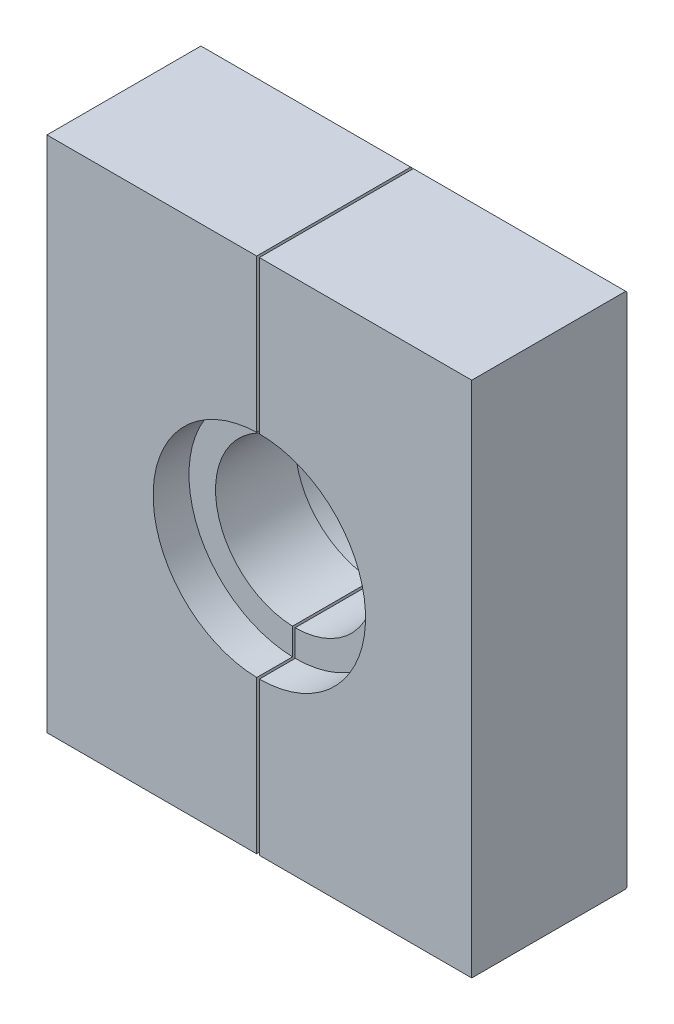
from build123d import *

# Parameters (mm, degrees)
SKICA1_W                  = 32
SKICA1_H                  = 39
SKICA1_R                  = 8
SKICA1_R_2                = 6
P_IDAT_VYSUNUT_M1_DEPTH   = 12.7
SKICA3_R                  = 8
ODEBRAT_VYSUNUT_M2_DEPTH  = 3.7
SKICA4_R                  = 8
ODEBRAT_VYSUNUT_M3_DEPTH  = 3
ZKOSEN_1_SIZE             = 0.1
ODEBRAT_START             = -12.7
SKICA10_W                 = 0.2
SKICA10_H                 = 39
ODEBRAT_VYSUNUT_M13_DEPTH = 12.7
SKETCH1_W                 = 58.510416229
SKETCH1_H                 = 45.106423975
CUT_EXTRUDE1_DEPTH        = 1


with BuildPart() as part:
    # Skica1 → Přidat vysunutím1 (new body)
    with BuildSketch(Plane.XY):
        with Locations((-2.081569801, -7.5)):
            Rectangle(SKICA1_W, SKICA1_H)
        with Locations((-2.081569801, -7.5)):
            Circle(SKICA1_R, mode=Mode.SUBTRACT)
        with Locations((-2.081569801, -7.5)):
            Circle(SKICA1_R)
        with Locations((-2.081569801, -7.5)):
            Circle(SKICA1_R_2, mode=Mode.SUBTRACT)
    extrude(amount=P_IDAT_VYSUNUT_M1_DEPTH)

    # Skica3 → Odebrat vysunutím2 (cut)
    with BuildSketch(Plane.XY.offset(12.7)):
        with Locations((-2.081569801, -7.5)):
            Circle(SKICA3_R)
    extrude(amount=-ODEBRAT_VYSUNUT_M2_DEPTH, mode=Mode.SUBTRACT)

    # Skica4 → Odebrat vysunutím3 (cut)
    with BuildSketch(Plane(origin=(0, 0, 0), x_dir=(-1, 0, 0), z_dir=(0, 0, -1))):
        with Locations((2.081569801, -7.5)):
            Circle(SKICA4_R)
    extrude(amount=-ODEBRAT_VYSUNUT_M3_DEPTH, mode=Mode.SUBTRACT)

    # Zkosení1
    zkosen_1_edges = [part.edges().sort_by_distance(p)[0] for p in [
        (-2.081569801, 12, 12.7),
        (-2.081569801, -27, 12.7),
        (-2.081569801, 12, 0),
        (-2.081569801, -27, 0),
    ]]
    chamfer(zkosen_1_edges, length=ZKOSEN_1_SIZE)

    # Skica10 → Odebrat vysunutím13 (cut)
    with BuildSketch(Plane.XY.offset(12.7).offset(ODEBRAT_START)):
        with Locations((-2.181569801, -7.5)):
            Rectangle(SKICA10_W, SKICA10_H)
    extrude(amount=ODEBRAT_VYSUNUT_M13_DEPTH, mode=Mode.SUBTRACT)

    # Sketch1 → Cut-Extrude1 (cut)
    with BuildSketch(Plane.XY.offset(12.7)):
        with Locations((-1.43113659, -7.98245449)):
            Rectangle(SKETCH1_W, SKETCH1_H)
    extrude(amount=-CUT_EXTRUDE1_DEPTH, mode=Mode.SUBTRACT)


solid = part.part
